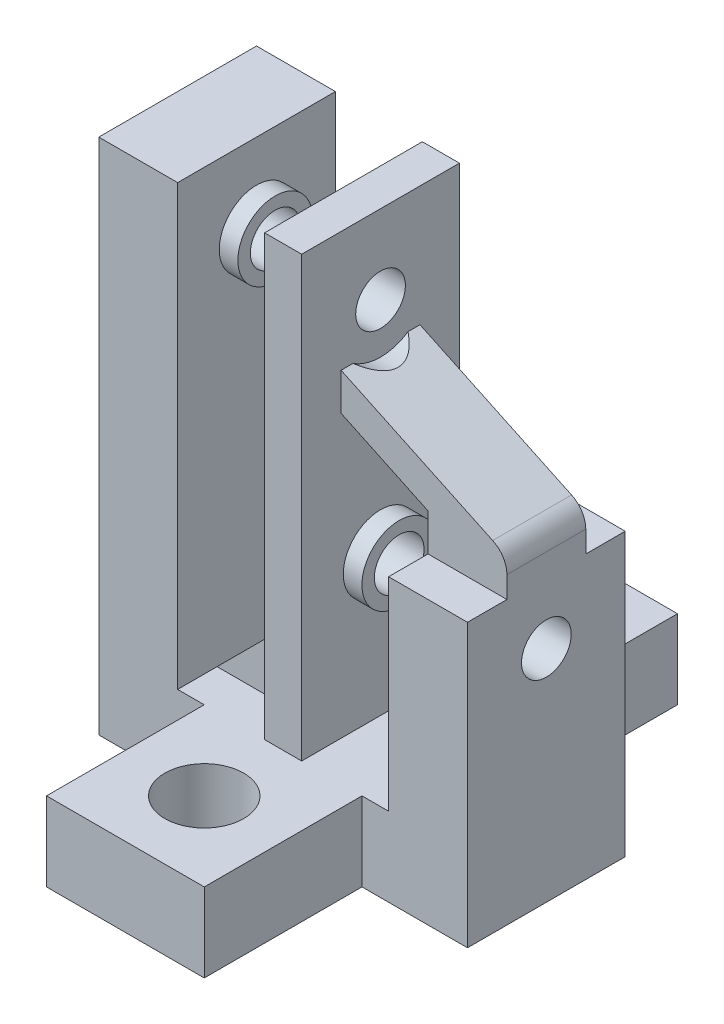
from build123d import *

# Parameters (mm, degrees)
SKETCH1_W            = 2.984999904
SKETCH1_H            = 41.686759908
BOSS_EXTRUDE1_DEPTH  = 12.7
SKETCH5_R            = 2
CUT_EXTRUDE2_DEPTH   = 3.984999904
SKETCH8_W            = 12.7
SKETCH8_H            = 6.35
BOSS_EXTRUDE2_DEPTH  = 12.7
SKETCH9_R            = 3.175
CUT_EXTRUDE3_DEPTH   = 12.7
SKETCH11_W           = 12.7
SKETCH11_H           = 6.35
BOSS_EXTRUDE3_DEPTH  = 12.7
CUT_EXTRUDE4_REACH   = 9.842
SKETCH12_R           = 2
SKETCH15_R           = 3
SKETCH15_R_2         = 2
BOSS_EXTRUDE5_DEPTH  = 1.5
SKETCH16_R           = 3
SKETCH16_R_2         = 2
BOSS_EXTRUDE6_DEPTH  = 1.5
SKETCH13_W           = 6.35
SKETCH13_H           = 41.686759908
SKETCH13_W_2         = 7
SKETCH13_H_2         = 6.35
BOSS_EXTRUDE4_DEPTH  = 6.35
SKETCH17_R           = 2
CUT_EXTRUDE5_DEPTH   = 29.685
SKETCH18_R           = 3
SKETCH18_R_2         = 2
BOSS_EXTRUDE7_DEPTH  = 1.5
SKETCH19_R           = 3
SKETCH19_R_2         = 2
BOSS_EXTRUDE8_DEPTH  = 1.5
CUT_EXTRUDE6_REACH   = 27.4
SKETCH20_W           = 6.35
SKETCH20_H           = 18.98776
SKETCH21_R           = 2
BOSS_EXTRUDE9_DEPTH  = 6.35
BOSS_EXTRUDE10_DEPTH = 3.175
BOSS_EXTRUDE11_DEPTH = 3.175
SKETCH24_R           = 4
CUT_EXTRUDE8_DEPTH   = 6.35
FILLET3_R            = 2


with BuildPart() as part:
    # Sketch1 → Boss-Extrude1 (new body)
    with BuildSketch(Plane.XY):
        Rectangle(SKETCH1_W, SKETCH1_H)
    extrude(amount=BOSS_EXTRUDE1_DEPTH)

    # Sketch5 → Cut-Extrude2 (cut, through all)
    with BuildSketch(Plane(origin=(1.492499952, 0, 0), x_dir=(0, 0, -1), z_dir=(1, 0, 0))):
        with Locations((-6.35, 14.493379954)):
            Circle(SKETCH5_R)
    extrude(amount=-CUT_EXTRUDE2_DEPTH, mode=Mode.SUBTRACT)

    # Sketch8 → Boss-Extrude2 (add)
    with BuildSketch(Plane.XY.offset(12.7)):
        with Locations((0, -17.668379954)):
            Rectangle(SKETCH8_W, SKETCH8_H)
    boss_extrude2 = extrude(amount=BOSS_EXTRUDE2_DEPTH)

    # Sketch9 → Cut-Extrude3 (cut)
    with BuildSketch(Plane(origin=(0, -14.493379954, 0), x_dir=(1, 0, 0), z_dir=(0, 1, 0))):
        with Locations((0, -19.05)):
            Circle(SKETCH9_R)
    cut_extrude3 = extrude(amount=-CUT_EXTRUDE3_DEPTH, mode=Mode.SUBTRACT)

    # Mirror1: Boss-Extrude2, Cut-Extrude3 across plane
    add(boss_extrude2.mirror(Plane(origin=(0, 0, 6.35), x_dir=(1, 0, 0), z_dir=(0, 0, -1))))
    add(cut_extrude3.mirror(Plane(origin=(0, 0, 6.35), x_dir=(1, 0, 0), z_dir=(0, 0, -1))), mode=Mode.SUBTRACT)

    # Sketch11 → Boss-Extrude3 (add)
    with BuildSketch(Plane(origin=(0, 0, 12.7), x_dir=(-1, 0, 0), z_dir=(0, 0, -1))):
        with Locations((0, -17.668379954)):
            Rectangle(SKETCH11_W, SKETCH11_H)
    extrude(amount=BOSS_EXTRUDE3_DEPTH)

    # Sketch12 → Cut-Extrude4 (cut, up to next)
    with BuildSketch(Plane(origin=(1.492499952, 0, 0), x_dir=(0, 0, -1), z_dir=(1, 0, 0)), mode=Mode.PRIVATE) as cut_extrude4_sk1:
        with Locations((-6.35, -3.144380046)):
            Circle(SKETCH12_R)
    cut_extrude4_tool1 = extrude(cut_extrude4_sk1.sketch, amount=-CUT_EXTRUDE4_REACH, mode=Mode.PRIVATE) & part.part
    add(cut_extrude4_tool1.solids().sort_by_distance((1.4925, -3.14438, 6.35))[0], mode=Mode.SUBTRACT)

    # Sketch15 → Boss-Extrude5 (add)
    with BuildSketch(Plane.ZY.offset(1.492499952)):
        with Locations((6.35, 14.493379954)):
            Circle(SKETCH15_R)
        with Locations((6.35, 14.493379954)):
            Circle(SKETCH15_R_2, mode=Mode.SUBTRACT)
    extrude(amount=BOSS_EXTRUDE5_DEPTH)

    # Sketch16 → Boss-Extrude6 (add)
    with BuildSketch(Plane(origin=(1.492499952, 0, 0), x_dir=(0, 0, -1), z_dir=(1, 0, 0))):
        with Locations((-6.35, -3.144380046)):
            Circle(SKETCH16_R)
        with Locations((-6.35, -3.144380046)):
            Circle(SKETCH16_R_2, mode=Mode.SUBTRACT)
    extrude(amount=BOSS_EXTRUDE6_DEPTH)

    # Sketch13 → Boss-Extrude4 (add, symmetric)
    with BuildSketch(Plane(origin=(0, 0, 6.35), x_dir=(-1, 0, 0), z_dir=(0, 0, -1))):
        with Locations((-11.667499952, 0)):
            Rectangle(SKETCH13_W, SKETCH13_H)
        with Locations((-4.992499952, -17.668379954)):
            Rectangle(SKETCH13_W_2, SKETCH13_H_2)
        with Locations((11.667499952, 0)):
            Rectangle(SKETCH13_W, SKETCH13_H)
        with Locations((4.992499952, -17.668379954)):
            Rectangle(SKETCH13_W_2, SKETCH13_H_2)
    extrude(amount=BOSS_EXTRUDE4_DEPTH, both=True)

    # Sketch17 → Cut-Extrude5 (cut)
    with BuildSketch(Plane.ZY.offset(14.842499952)):
        with Locations((6.35, 14.493379954)):
            Circle(SKETCH17_R)
        with Locations((6.35, -3.144380046)):
            Circle(SKETCH17_R)
    extrude(amount=-CUT_EXTRUDE5_DEPTH, mode=Mode.SUBTRACT)

    # Sketch18 → Boss-Extrude7 (add)
    with BuildSketch(Plane.ZY.offset(-8.492499952)):
        with Locations((6.35, -3.144380046)):
            Circle(SKETCH18_R)
        with Locations((6.35, -3.144380046)):
            Circle(SKETCH18_R_2, mode=Mode.SUBTRACT)
    extrude(amount=BOSS_EXTRUDE7_DEPTH)

    # Sketch19 → Boss-Extrude8 (add)
    with BuildSketch(Plane(origin=(-8.492499952, 0, 0), x_dir=(0, 0, -1), z_dir=(1, 0, 0))):
        with Locations((-6.35, 14.493379954)):
            Circle(SKETCH19_R)
        with Locations((-6.35, 14.493379954)):
            Circle(SKETCH19_R_2, mode=Mode.SUBTRACT)
    extrude(amount=BOSS_EXTRUDE8_DEPTH)

    # Sketch20 → Cut-Extrude6 (cut, up to next)
    with BuildSketch(Plane(origin=(0, 0, 0), x_dir=(-1, 0, 0), z_dir=(0, 0, -1)), mode=Mode.PRIVATE) as cut_extrude6_sk1:
        with Locations((-11.667499952, 11.349499954)):
            Rectangle(SKETCH20_W, SKETCH20_H)
    cut_extrude6_tool1 = extrude(cut_extrude6_sk1.sketch, amount=-CUT_EXTRUDE6_REACH, mode=Mode.PRIVATE) & part.part
    add(cut_extrude6_tool1.solids().sort_by_distance((11.6675, 11.3495, 0))[0], mode=Mode.SUBTRACT)

    # Sketch21 → Boss-Extrude9 (add)
    with BuildSketch(Plane.ZY.offset(14.842499952)):
        with Locations((6.35, -3.144380046)):
            Circle(SKETCH21_R)
    extrude(amount=-BOSS_EXTRUDE9_DEPTH)

    # Sketch22 → Boss-Extrude10 (add, symmetric)
    with BuildSketch(Plane.XY.offset(6.35)):
        Polygon((8.492499952, 1.855619954), (14.842499952, 1.855619954), (14.842499952, 4.855619954), (1.492499952, 11.162706568), (1.492499952, 8.162706568), (8.492499952, 4.855619954), align=None)
    extrude(amount=BOSS_EXTRUDE10_DEPTH, both=True)

    # Sketch23 → Boss-Extrude11 (add, symmetric)
    with BuildSketch(Plane(origin=(0, 0, 6.35), x_dir=(-1, 0, 0), z_dir=(0, 0, -1))):
        Polygon((1.492499952, -7.493379954), (8.492499952, -14.493379954), (1.492499952, -14.493379954), align=None)
    extrude(amount=BOSS_EXTRUDE11_DEPTH, both=True)

    # Sketch24 → Cut-Extrude8 (cut)
    with BuildSketch(Plane(origin=(1.492499952, 0, 0), x_dir=(0, 0, -1), z_dir=(1, 0, 0))):
        with Locations((-6.35, 14.493379954)):
            Circle(SKETCH24_R)
    extrude(amount=CUT_EXTRUDE8_DEPTH, mode=Mode.SUBTRACT)

    # Fillet3
    fillet3_edges = [part.edges().sort_by_distance(p)[0] for p in [
        (14.842499952, 4.855619954, 6.35),
    ]]
    fillet(fillet3_edges, radius=FILLET3_R)


solid = part.part
